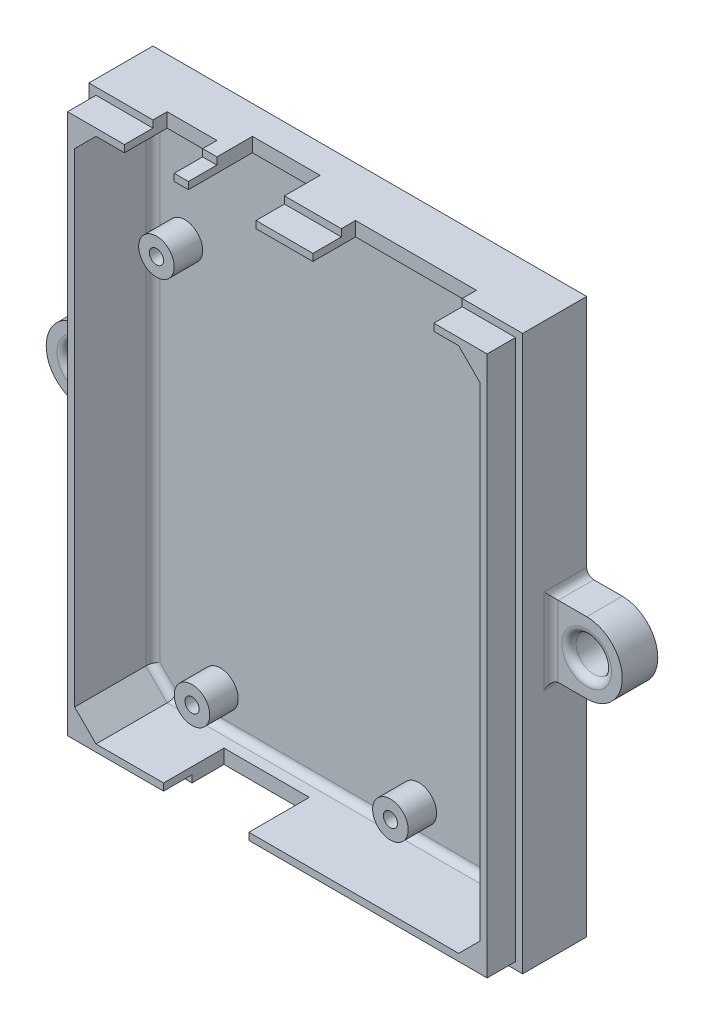
from build123d import *

# Parameters (mm, degrees)
ESQUISSE1_W             = 61
ESQUISSE1_H             = 78
BOSS_EXTRU_1_DEPTH      = 2
ESQUISSE2_W             = 61
ESQUISSE2_H             = 78
ESQUISSE2_W_2           = 57
ESQUISSE2_H_2           = 74
BOSS_EXTRU_2_DEPTH      = 7
ESQUISSE3_W             = 59
ESQUISSE3_H             = 76
ESQUISSE3_W_2           = 57
ESQUISSE3_H_2           = 74
BOSS_EXTRU_3_DEPTH      = 4
ESQUISSE4_R             = 2.5
BOSS_EXTRU_4_DEPTH      = 4
ESQUISSE6_W             = 12
ESQUISSE6_H             = 20
ENL_V_MAT_EXTRU_1_DEPTH = 3
ESQUISSE7_W             = 17
ESQUISSE7_H             = 13
ESQUISSE7_W_2           = 9.5
ESQUISSE7_H_2           = 16
ESQUISSE7_W_3           = 7
ENL_V_MAT_EXTRU_2_DEPTH = 3
ESQUISSE5_R             = 1
ENL_V_MAT_EXTRU_3_DEPTH = 4
CHANFREIN1_SIZE         = 3
BOSS_EXTRU_5_DEPTH      = 5
ENL_V_MAT_EXTRU_4_REACH = 7
ESQUISSE9_R             = 2.5
CONG_1_R                = 1
CONG_2_R                = 1
CONG_3_R                = 1


with BuildPart() as part:
    # Esquisse1 → Boss.-Extru.1 (new body)
    with BuildSketch(Plane.XY):
        Rectangle(ESQUISSE1_W, ESQUISSE1_H)
    extrude(amount=BOSS_EXTRU_1_DEPTH)

    # Esquisse2 → Boss.-Extru.2 (add)
    with BuildSketch(Plane.XY.offset(2)):
        Rectangle(ESQUISSE2_W, ESQUISSE2_H)
        Rectangle(ESQUISSE2_W_2, ESQUISSE2_H_2, mode=Mode.SUBTRACT)
    extrude(amount=BOSS_EXTRU_2_DEPTH)

    # Esquisse3 → Boss.-Extru.3 (add)
    with BuildSketch(Plane.XY.offset(9)):
        Rectangle(ESQUISSE3_W, ESQUISSE3_H)
        Rectangle(ESQUISSE3_W_2, ESQUISSE3_H_2, mode=Mode.SUBTRACT)
    extrude(amount=BOSS_EXTRU_3_DEPTH)

    # Esquisse4 → Boss.-Extru.4 (add)
    with BuildSketch(Plane.XY.offset(2)):
        with Locations((-24, 19.6)):
            Circle(ESQUISSE4_R)
        with Locations((24.2, 18.3)):
            Circle(ESQUISSE4_R)
        with Locations((8.9, -32.5)):
            Circle(ESQUISSE4_R)
        with Locations((-19, -32.5)):
            Circle(ESQUISSE4_R)
    extrude(amount=BOSS_EXTRU_4_DEPTH)

    # Esquisse6 → Enlèv. mat.-Extru.1 (cut)
    with BuildSketch(Plane.XZ.offset(39)):
        with Locations((-10, 14.5)):
            Rectangle(ESQUISSE6_W, ESQUISSE6_H)
    extrude(amount=-ENL_V_MAT_EXTRU_1_DEPTH, mode=Mode.SUBTRACT)

    # Esquisse7 → Enlèv. mat.-Extru.2 (cut)
    with BuildSketch(Plane(origin=(0, 39, 0), x_dir=(1, 0, 0), z_dir=(0, 1, 0))):
        with Locations((13.5, -13.5)):
            Rectangle(ESQUISSE7_W, ESQUISSE7_H)
        with Locations((-7.75, -12)):
            Rectangle(ESQUISSE7_W_2, ESQUISSE7_H_2)
        with Locations((-18, -13.5)):
            Rectangle(ESQUISSE7_W_3, ESQUISSE7_H)
    extrude(amount=-ENL_V_MAT_EXTRU_2_DEPTH, mode=Mode.SUBTRACT)

    # Esquisse5 → Enlèv. mat.-Extru.3 (cut)
    with BuildSketch(Plane.XY.offset(6)):
        with Locations((-24, 19.6)):
            Circle(ESQUISSE5_R)
        with Locations((24.2, 18.3)):
            Circle(ESQUISSE5_R)
        with Locations((8.9, -32.5)):
            Circle(ESQUISSE5_R)
        with Locations((-19, -32.5)):
            Circle(ESQUISSE5_R)
    extrude(amount=-ENL_V_MAT_EXTRU_3_DEPTH, mode=Mode.SUBTRACT)

    # Chanfrein1
    chanfrein1_edges = [part.edges().sort_by_distance(p)[0] for p in [
        (-28.5, -37, 7.5),
        (28.5, -37, 7.5),
        (28.5, 37, 7.5),
        (-28.5, 37, 7.5),
    ]]
    chamfer(chanfrein1_edges, length=CHANFREIN1_SIZE)

    # Esquisse8 → Boss.-Extru.5 (add)
    with BuildSketch(Plane(origin=(0, 0, 0), x_dir=(-1, 0, 0), z_dir=(0, 0, -1))):
        with BuildLine():
            Line((-30.5, 5), (-35.5, 5))
            ThreePointArc((-35.5, 5), (-40.5, 0), (-35.5, -5))
            Line((-35.5, -5), (-30.5, -5))
            Line((-30.5, -5), (-30.5, 5))
        make_face()
        with BuildLine():
            Line((30.5, -5), (35.5, -5))
            ThreePointArc((35.5, -5), (40.5, 0), (35.5, 5))
            Line((35.5, 5), (30.5, 5))
            Line((30.5, 5), (30.5, -5))
        make_face()
    extrude(amount=-BOSS_EXTRU_5_DEPTH)

    # Esquisse9 → Enlèv. mat.-Extru.4 (cut, up to next)
    with BuildSketch(Plane.XY.offset(5), mode=Mode.PRIVATE) as enl_v_mat_extru_4_sk1:
        with Locations((-35.5, 0)):
            Circle(ESQUISSE9_R)
    enl_v_mat_extru_4_tool1 = extrude(enl_v_mat_extru_4_sk1.sketch, amount=-ENL_V_MAT_EXTRU_4_REACH, mode=Mode.PRIVATE) & part.part
    add(enl_v_mat_extru_4_tool1.solids().sort_by_distance((-35.5, 0, 5))[0], mode=Mode.SUBTRACT)
    # Esquisse9 → Enlèv. mat.-Extru.4 (cut, up to next)
    with BuildSketch(Plane.XY.offset(5), mode=Mode.PRIVATE) as enl_v_mat_extru_4_sk2:
        with Locations((35.5, 0)):
            Circle(ESQUISSE9_R)
    enl_v_mat_extru_4_tool2 = extrude(enl_v_mat_extru_4_sk2.sketch, amount=-ENL_V_MAT_EXTRU_4_REACH, mode=Mode.PRIVATE) & part.part
    add(enl_v_mat_extru_4_tool2.solids().sort_by_distance((35.5, 0, 5))[0], mode=Mode.SUBTRACT)

    # Congé1
    cong_1_edges = [part.edges().sort_by_distance(p)[0] for p in [
        (-38, 0, 5),
        (33, 0, 5),
    ]]
    fillet(cong_1_edges, radius=CONG_1_R)

    # Congé2
    cong_2_edges = [part.edges().sort_by_distance(p)[0] for p in [
        (30.5, -5, 2.5),
        (30.5, 5, 2.5),
        (30.5, 0, 5),
        (-30.5, 5, 2.5),
        (-30.5, -5, 2.5),
        (-30.5, 0, 5),
    ]]
    fillet(cong_2_edges, radius=CONG_2_R)

    # Congé3
    cong_3_edges = [part.edges().sort_by_distance(p)[0] for p in [
        (0, -37, 2),
        (-28.5, 0, 2),
        (28.5, 0, 2),
        (0, 37, 2),
        (-27, -35.5, 2),
        (-27, 35.5, 2),
        (27, 35.5, 2),
        (27, -35.5, 2),
    ]]
    fillet(cong_3_edges, radius=CONG_3_R)


solid = part.part
